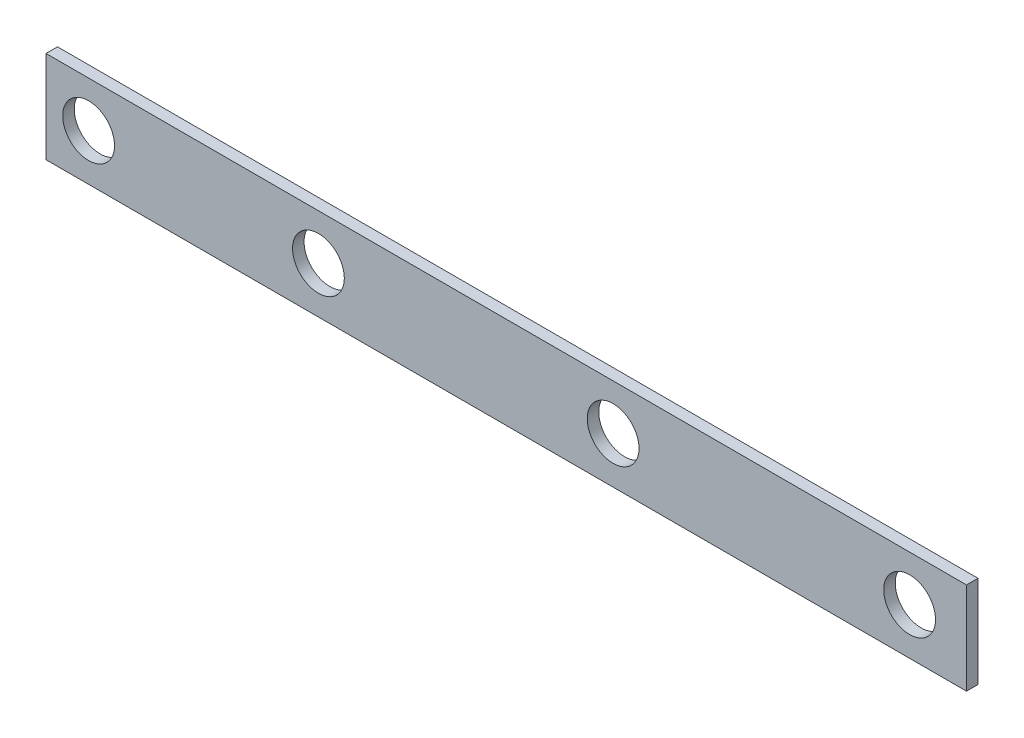
from build123d import *

# Parameters (mm, degrees)
SKETCH1_W           = 508
SKETCH1_H           = 50.8
BOSS_EXTRUDE1_DEPTH = 6.35
SKETCH2_R           = 14.2875
CUT_EXTRUDE1_DEPTH  = 6.35


with BuildPart() as part:
    # Sketch1 → Boss-Extrude1 (new body)
    with BuildSketch(Plane.XY):
        with Locations((-42.652830189, 117.894339623)):
            Rectangle(SKETCH1_W, SKETCH1_H)
    extrude(amount=BOSS_EXTRUDE1_DEPTH)

    # Sketch2 → Cut-Extrude1 (cut)
    with BuildSketch(Plane.XY.offset(6.35)):
        with Locations((-273.13155321, 118.145560078)):
            Circle(SKETCH2_R)
        with Locations((179.961208928, 118.145560078)):
            Circle(SKETCH2_R)
        with Locations((-146.306982812, 118.145560078)):
            Circle(SKETCH2_R)
        with Locations((16.330659438, 118.145560078)):
            Circle(SKETCH2_R)
    extrude(amount=-CUT_EXTRUDE1_DEPTH, mode=Mode.SUBTRACT)


solid = part.part
